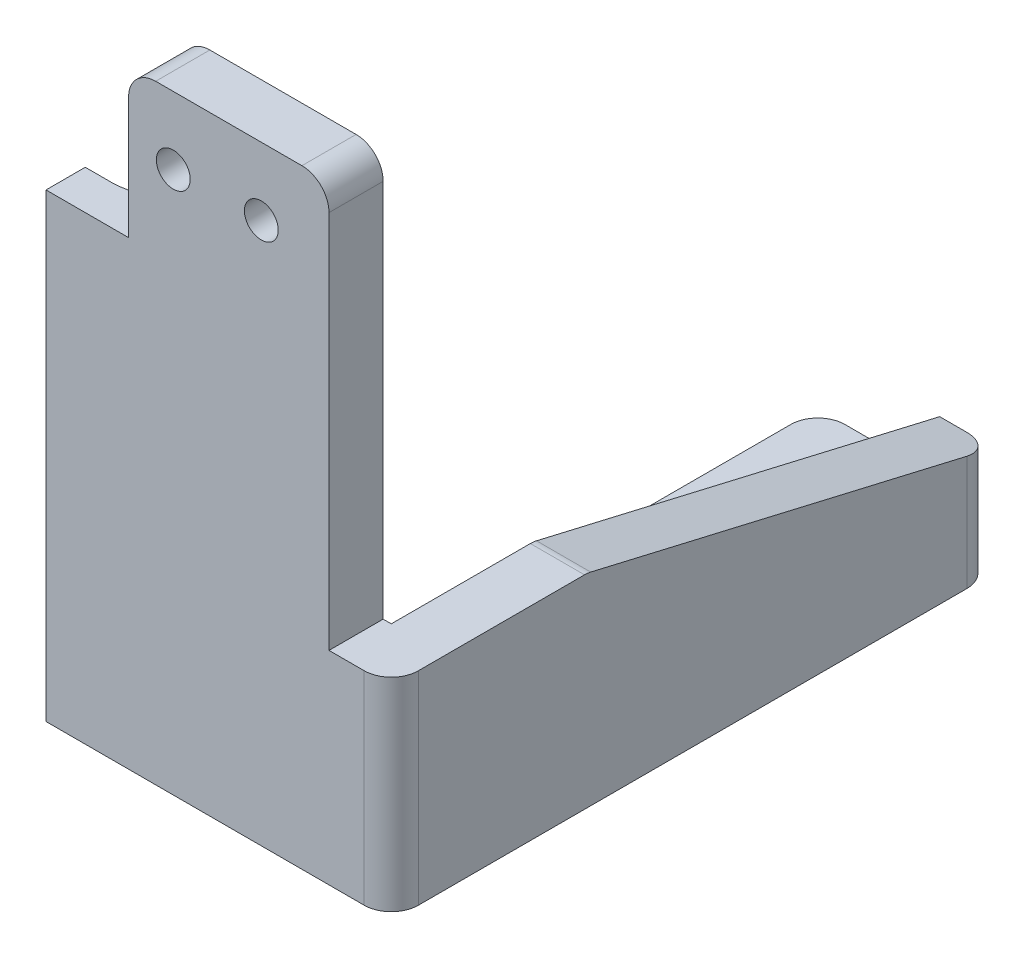
from build123d import *

# Parameters (mm, degrees)
SKETCH1_W           = 14.8
SKETCH1_H           = 45
SKETCH1_R           = 1.25
BOSS_EXTRUDE1_DEPTH = 2
BOSS_EXTRUDE2_DEPTH = 34
CHAMFER2_SIZE       = 5
SKETCH3_W           = 9
SKETCH3_H           = 44.5
SKETCH3_R           = 1.75
BOSS_EXTRUDE3_DEPTH = 4
BOSS_EXTRUDE4_DEPTH = 15
CHAMFER3_SIZE       = 7
CHAMFER3_SIZE2      = 30
FILLET3_R           = 2
FILLET4_R           = 2


with BuildPart() as part:
    # Sketch1 → Boss-Extrude1 (new body, symmetric)
    with BuildSketch(Plane.XY):
        with Locations((0.85, -17.5)):
            Rectangle(SKETCH1_W, SKETCH1_H)
        with Locations((-3.25, 0)):
            Circle(SKETCH1_R, mode=Mode.SUBTRACT)
        with Locations((3.25, 0)):
            Circle(SKETCH1_R, mode=Mode.SUBTRACT)
    extrude(amount=BOSS_EXTRUDE1_DEPTH, both=True)

    # Sketch2 → Boss-Extrude2 (add)
    with BuildSketch(Plane.XZ.offset(40)):
        with BuildLine():
            Line((-6.55, -2), (-6.55, 2))
            Line((-6.55, 2), (-12.65, 2))
            Line((-12.65, 2), (-12.65, -0.9))
            Line((-12.65, -0.9), (-10.65, -0.9))
            ThreePointArc((-10.65, -0.9), (-6.55, -5), (-10.65, -9.1))
            Line((-10.65, -9.1), (-12.65, -9.1))
            Line((-12.65, -9.1), (-12.65, -10.9))
            Line((-12.65, -10.9), (0.45, -10.9))
            Line((0.45, -10.9), (0.45, -2))
            Line((0.45, -2), (-6.55, -2))
        make_face()
    extrude(amount=-BOSS_EXTRUDE2_DEPTH)

    # Chamfer2
    chamfer2_edges = [part.edges().sort_by_distance(p)[0] for p in [
        (0.45, -23, -10.9),
    ]]
    chamfer(chamfer2_edges, length=CHAMFER2_SIZE)

    # Sketch3 → Boss-Extrude3 (add)
    with BuildSketch(Plane.XZ.offset(40)):
        with Locations((4.35, -20.25)):
            Rectangle(SKETCH3_W, SKETCH3_H)
        with Locations((4.35, -37.5)):
            Circle(SKETCH3_R, mode=Mode.SUBTRACT)
        with Locations((4.35, -6.5)):
            Circle(SKETCH3_R, mode=Mode.SUBTRACT)
    extrude(amount=-BOSS_EXTRUDE3_DEPTH)

    # Sketch4 → Boss-Extrude4 (add)
    with BuildSketch(Plane(origin=(0, -40, 0), x_dir=(-1, 0, 0), z_dir=(0, 1, 0))):
        Polygon((-8.85, -42.5), (-12.85, -42.5), (-12.85, 2), (-8.85, 2), (-8.25, 2), (-8.25, -2), (-8.85, -2), align=None)
    extrude(amount=BOSS_EXTRUDE4_DEPTH)

    # Chamfer3
    chamfer3_edges = [part.edges().sort_by_distance(p)[0] for p in [
        (10.85, -25, -42.5),
    ]]
    chamfer3_side = [part.faces().sort_by_distance(p)[0] for p in [
        (0.048494332, -38, -42.5),
    ]]
    chamfer(chamfer3_edges, length=CHAMFER3_SIZE, length2=CHAMFER3_SIZE2, reference=chamfer3_side[0])

    # Fillet3
    fillet3_edges = [part.edges().sort_by_distance(p)[0] for p in [
        (10.85, -25, -12.5),
        (12.85, -36, -42.5),
        (-0.15, -38, -42.5),
        (12.85, -32.5, 2),
    ]]
    fillet(fillet3_edges, radius=FILLET3_R)

    # Fillet4
    fillet4_edges = [part.edges().sort_by_distance(p)[0] for p in [
        (-6.55, 5, 0),
        (8.25, 5, 0),
    ]]
    fillet(fillet4_edges, radius=FILLET4_R)


solid = part.part
